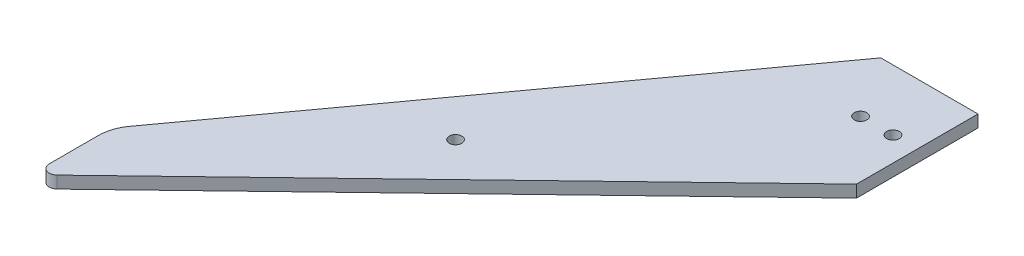
from build123d import *

# Parameters (mm, degrees)
SKETCH1_W           = 24
SKETCH1_H           = 30
BOSS_EXTRUDE1_DEPTH = 1.5
SKETCH2_R           = 1.55
CUT_EXTRUDE1_DEPTH  = 3
FILLET1_R           = 10
FILLET2_R           = 2


with BuildPart() as part:
    # Sketch1 → Boss-Extrude1 (new body, symmetric)
    with BuildSketch(Plane(origin=(0, 0, 0), x_dir=(1, 0, 0), z_dir=(0, 1, 0))):
        Polygon((-92, -95), (-92, -115), (12, -15), (-12, -15), (-12, 15), align=None)
        Rectangle(SKETCH1_W, SKETCH1_H)
    extrude(amount=BOSS_EXTRUDE1_DEPTH, both=True)

    # Sketch2 → Cut-Extrude1 (cut)
    with BuildSketch(Plane(origin=(0, 1.5, 0), x_dir=(1, 0, 0), z_dir=(0, 1, 0))):
        with Locations((6, 0)):
            Circle(SKETCH2_R)
        with Locations((-2, 0)):
            Circle(SKETCH2_R)
        with Locations((-47, -55)):
            Circle(SKETCH2_R)
    extrude(amount=-CUT_EXTRUDE1_DEPTH, mode=Mode.SUBTRACT)

    # Fillet1
    fillet1_edges = [part.edges().sort_by_distance(p)[0] for p in [
        (-92, 0, 95),
    ]]
    fillet(fillet1_edges, radius=FILLET1_R)

    # Fillet2
    fillet2_edges = [part.edges().sort_by_distance(p)[0] for p in [
        (-92, 0, 115),
    ]]
    fillet(fillet2_edges, radius=FILLET2_R)


solid = part.part
